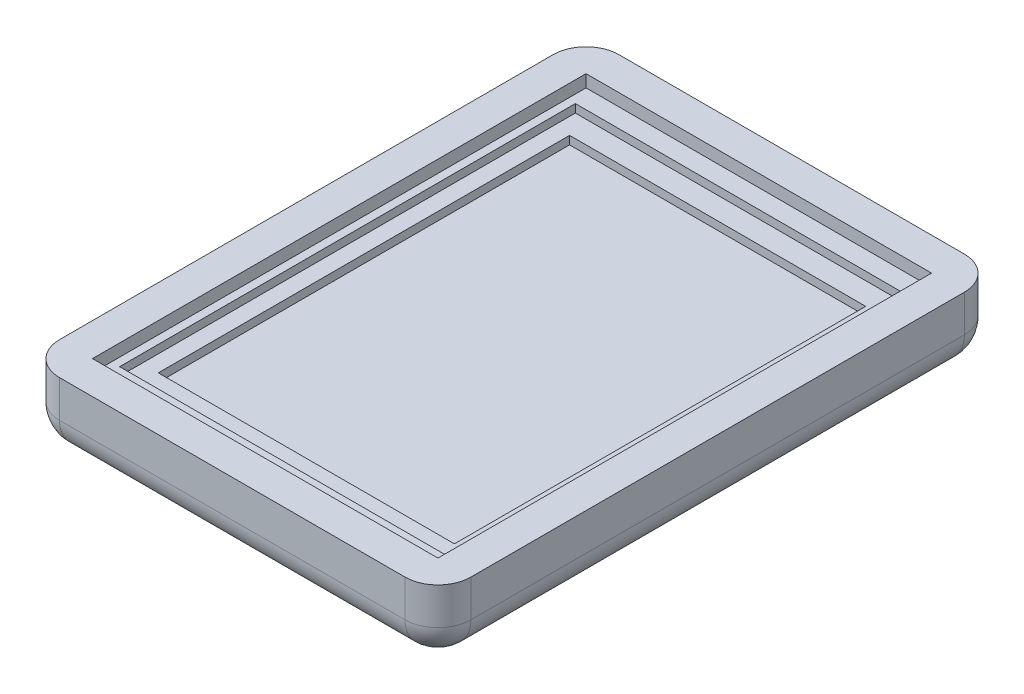
from build123d import *

# Parameters (mm, degrees)
SKETCH1_W           = 5.08
SKETCH1_H           = 5.08
BOSS_EXTRUDE1_DEPTH = 5.715
SKETCH2_W           = 63.5
SKETCH2_H           = 86.36
BOSS_EXTRUDE2_DEPTH = 5.08
FILLET1_R           = 5.08
SKETCH3_W           = 53.34
SKETCH3_H           = 76.2
BOSS_EXTRUDE3_DEPTH = 3.81
CUT_EXTRUDE1_DEPTH  = 1.27
SKETCH6_W           = 45.72
SKETCH6_H           = 63.5
CUT_EXTRUDE2_DEPTH  = 2.54


with BuildPart() as part:
    # Sketch1 → Boss-Extrude1 (new body)
    with BuildSketch(Plane(origin=(0, 0, 0), x_dir=(1, 0, 0), z_dir=(0, 1, 0))):
        Polygon((-5.08, 0), (0, 0), (0, 76.2), (53.34, 76.2), (53.34, 81.28), (-5.08, 81.28), align=None)
        Polygon((53.34, 0), (0, 0), (0, -5.08), (58.42, -5.08), (58.42, 76.2), (53.34, 76.2), align=None)
        with Locations((-2.54, -2.54)):
            Rectangle(SKETCH1_W, SKETCH1_H)
        with Locations((55.88, 78.74)):
            Rectangle(SKETCH1_W, SKETCH1_H)
    extrude(amount=-BOSS_EXTRUDE1_DEPTH)

    # Sketch2 → Boss-Extrude2 (add)
    with BuildSketch(Plane(origin=(0, -5.715, 0), x_dir=(-1, 0, 0), z_dir=(0, -1, 0))):
        with Locations((-26.67, 38.1)):
            Rectangle(SKETCH2_W, SKETCH2_H)
    extrude(amount=BOSS_EXTRUDE2_DEPTH)

    # Fillet1
    fillet1_edges = [part.edges().sort_by_distance(p)[0] for p in [
        (-5.08, -5.3975, 5.08),
        (-5.08, -5.3975, -81.28),
        (58.42, -5.3975, -81.28),
        (58.42, -5.3975, 5.08),
        (-5.08, -10.795, -38.1),
        (26.67, -10.795, -81.28),
        (58.42, -10.795, -38.1),
        (26.67, -10.795, 5.08),
    ]]
    fillet(fillet1_edges, radius=FILLET1_R)

    # Sketch3 → Boss-Extrude3 (add)
    with BuildSketch(Plane(origin=(0, -5.715, 0), x_dir=(1, 0, 0), z_dir=(0, 1, 0))):
        with Locations((26.67, 38.1)):
            Rectangle(SKETCH3_W, SKETCH3_H)
    extrude(amount=BOSS_EXTRUDE3_DEPTH)

    # Sketch4 → Cut-Extrude1 (cut)
    with BuildSketch(Plane(origin=(0, -1.905, 0), x_dir=(1, 0, 0), z_dir=(0, 1, 0))):
        Polygon((48.895, 69.85), (51.2953, 73.279), (2.0447, 73.279), (4.445, 69.85), align=None)
        Polygon((52.07, 73.279), (51.2953, 73.279), (48.895, 69.85), (49.53, 69.85), (49.53, 6.35), (48.895, 6.35), (51.2953, 2.921), (52.07, 2.921), align=None)
        Polygon((48.895, 6.35), (4.445, 6.35), (2.0447, 2.921), (51.2953, 2.921), align=None)
        Polygon((4.445, 69.85), (2.0447, 73.279), (1.27, 73.279), (1.27, 2.921), (2.0447, 2.921), (4.445, 6.35), (3.81, 6.35), (3.81, 69.85), align=None)
    extrude(amount=-CUT_EXTRUDE1_DEPTH, mode=Mode.SUBTRACT)

    # Sketch6 → Cut-Extrude2 (cut)
    with BuildSketch(Plane(origin=(0, -1.905, 0), x_dir=(1, 0, 0), z_dir=(0, 1, 0))):
        with Locations((26.67, 38.1)):
            Rectangle(SKETCH6_W, SKETCH6_H)
    extrude(amount=-CUT_EXTRUDE2_DEPTH, mode=Mode.SUBTRACT)


solid = part.part
